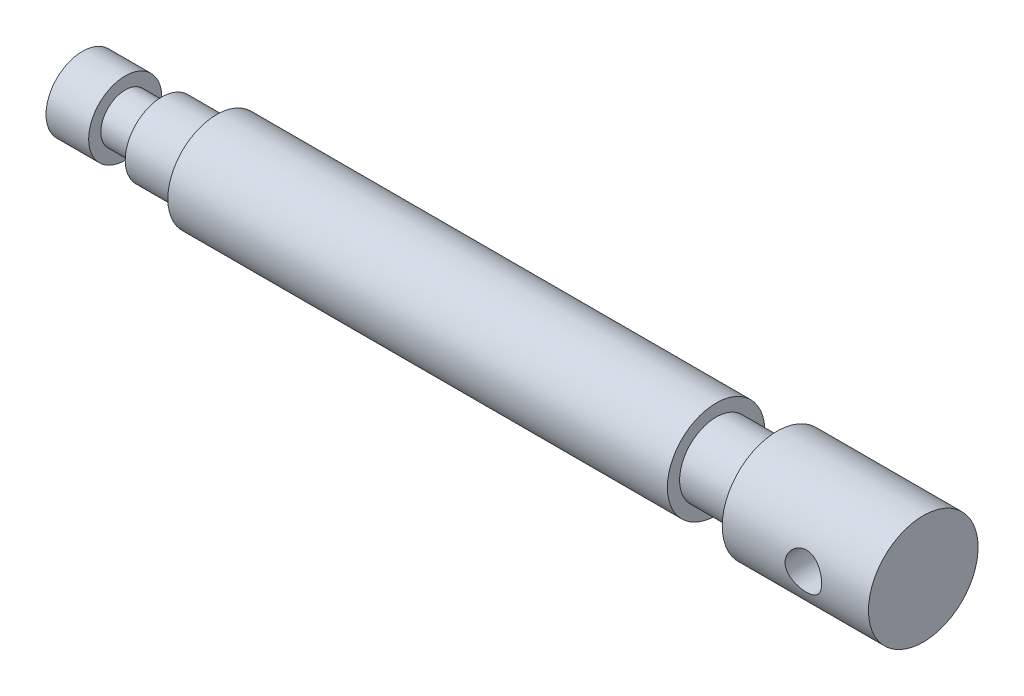
from build123d import *

# Parameters (mm, degrees)
SKETCH2_W          = 10
SKETCH2_H          = 6
SKETCH2_W_2        = 6
SKETCH2_H_2        = 4
SKETCH3_R          = 3
CUT_EXTRUDE1_DEPTH = 140.45967159


with BuildPart() as part:
    # Sketch2 → Revolve1 (revolve)
    with BuildSketch(Plane.XY, mode=Mode.PRIVATE) as revolve1_sk:
        Polygon((22, 6), (22, 0), (104, 0), (104, 6), (104, 8), (22, 8), align=None)
        with Locations((109, 3)):
            Rectangle(SKETCH2_W, SKETCH2_H)
        with BuildLine():
            Line((114, 6), (114, 0))
            Line((114, 0), (123, 0))
            ThreePointArc((123, 0), (126, 3), (129, 0))
            Line((129, 0), (138, 0))
            Line((138, 0), (138, 9))
            Line((138, 9), (114, 9))
            Line((114, 9), (114, 6))
        make_face()
        Polygon((13, 4), (13, 0), (22, 0), (22, 6), (13, 6), align=None)
        Polygon((0, 6), (0, 0), (7, 0), (7, 4), (7, 6), align=None)
        with Locations((10, 2)):
            Rectangle(SKETCH2_W_2, SKETCH2_H_2)
    revolve(revolve1_sk.sketch.rotate(Axis((-35.742937112, 0, 0), (1, 0, 0)), 90), axis=Axis((-35.742937112, 0, 0), (1, 0, 0)))

    # Sketch3 → Cut-Extrude1 (cut, through all)
    with BuildSketch(Plane.XY.offset(9)):
        with Locations((127.319310505, 0)):
            Circle(SKETCH3_R)
    extrude(amount=-CUT_EXTRUDE1_DEPTH, mode=Mode.SUBTRACT)


solid = part.part
